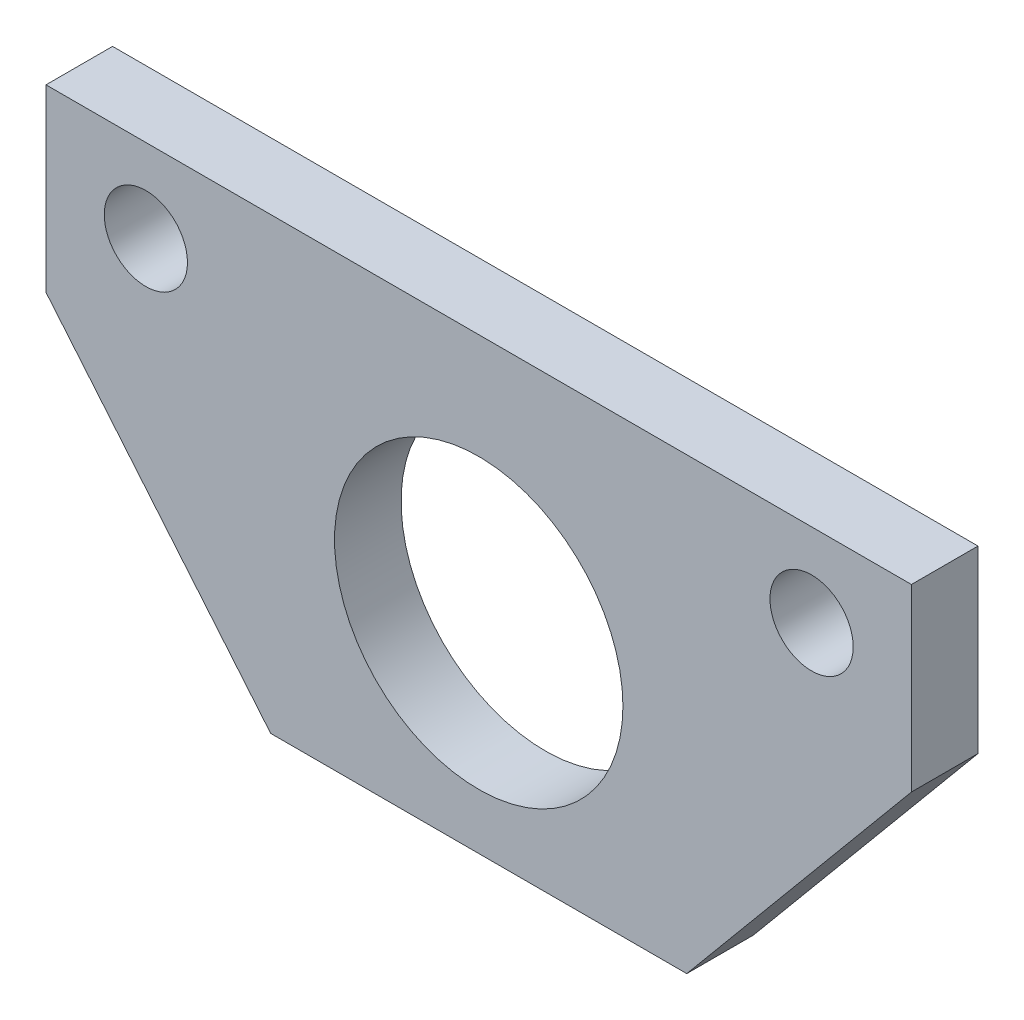
from build123d import *

# Parameters (mm, degrees)
BOSS_EXTRUDE1_DEPTH = 5.08
SKETCH3_R           = 11.00455
SKETCH3_R_2         = 3.175
CUT_EXTRUDE2_DEPTH  = 5.08
SKETCH4_W           = 38.1
SKETCH4_H           = 3.81
CUT_EXTRUDE3_DEPTH  = 6.08


with BuildPart() as part:
    # Sketch1 → Boss-Extrude1 (new body)
    with BuildSketch(Plane.XY):
        Polygon((-44.45, 38.1), (44.45, 38.1), (12.7, 0), (-12.7, 0), align=None)
    extrude(amount=BOSS_EXTRUDE1_DEPTH)

    # Sketch3 → Cut-Extrude2 (cut)
    with BuildSketch(Plane.XY.offset(5.08)):
        with Locations((0, 19.05)):
            Circle(SKETCH3_R)
        with Locations((-25.4, 31.75)):
            Circle(SKETCH3_R_2)
        with Locations((25.4, 31.75)):
            Circle(SKETCH3_R_2)
        Polygon((-33.02, 24.384), (-33.02, 38.1), (-44.45, 38.1), align=None)
        Polygon((33.02, 38.1), (33.02, 24.384), (44.45, 38.1), align=None)
    extrude(amount=-CUT_EXTRUDE2_DEPTH, mode=Mode.SUBTRACT)

    # Sketch4 → Cut-Extrude3 (cut, through all)
    with BuildSketch(Plane.XY.offset(5.08)):
        with Locations((0, 1.905)):
            Rectangle(SKETCH4_W, SKETCH4_H)
    extrude(amount=-CUT_EXTRUDE3_DEPTH, mode=Mode.SUBTRACT)


solid = part.part
